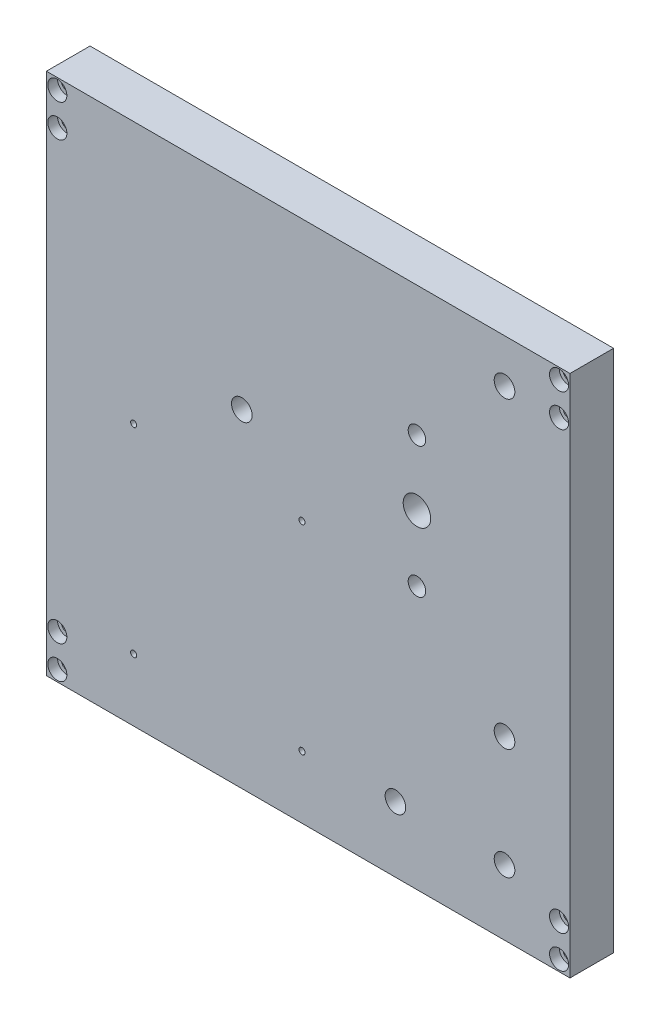
from build123d import *

# Parameters (mm, degrees)
SKETCH1_W                                      = 152.4
SKETCH1_H                                      = 152.4
BOSS_EXTRUDE1_DEPTH                            = 12.7
F_2_56_TAPPED_HOLE1_D                          = 1.778
CBORE_FOR_4_SOCKET_HEAD_CAP_SCREW1_D           = 3.2639
CBORE_FOR_4_SOCKET_HEAD_CAP_SCREW1_CBORE_D     = 5.55752
CBORE_FOR_4_SOCKET_HEAD_CAP_SCREW1_CBORE_DEPTH = 2.8448
F_6_0MM_DOWEL_HOLE1_D                          = 6
F_8_0MM_DOWEL_HOLE1_D                          = 8
F_1_4_20_TAPPED_HOLE1_D                        = 5.1054


with BuildPart() as part:
    # Sketch1 → Boss-Extrude1 (new body)
    with BuildSketch(Plane.XY):
        Rectangle(SKETCH1_W, SKETCH1_H)
    extrude(amount=BOSS_EXTRUDE1_DEPTH)

    # #2-56 Tapped Hole1 (through all)
    with Locations(Plane.XY.offset(12.7)):
        with Locations((-50.8, 0), (-50.8, -58), (-1.8, -58), (-1.8, 0)):
            Hole(F_2_56_TAPPED_HOLE1_D / 2)

    # CBORE for #4 Socket Head Cap Screw1 (through all)
    with Locations(Plane.XY.offset(12.7)):
        with Locations((-73.025, 63.5), (-73.025, 73.025), (73.025, 63.5), (73.025, 73.025), (73.025, -63.5), (73.025, -73.025), (-73.025, -63.5), (-73.025, -73.025)):
            CounterBoreHole(CBORE_FOR_4_SOCKET_HEAD_CAP_SCREW1_D / 2, CBORE_FOR_4_SOCKET_HEAD_CAP_SCREW1_CBORE_D / 2, CBORE_FOR_4_SOCKET_HEAD_CAP_SCREW1_CBORE_DEPTH)

    # Ø6.0mm Dowel Hole1 (through all)
    with Locations(Plane.XY.offset(12.7)):
        with Locations((57.15, 63.5), (57.15, -24.801), (-19.32090918, 19.3495), (57.15, -57.15), (25.4, -57.15)):
            Hole(F_6_0MM_DOWEL_HOLE1_D / 2)

    # Ø8.0mm Dowel Hole1 (through all)
    with Locations(Plane.XY.offset(12.7)):
        with Locations((31.65969694, 19.3495)):
            Hole(F_8_0MM_DOWEL_HOLE1_D / 2)

    # 1/4-20 Tapped Hole1 (through all)
    with Locations(Plane.XY.offset(12.7)):
        with Locations((31.65969694, 0.2995), (31.65969694, 38.3995)):
            Hole(F_1_4_20_TAPPED_HOLE1_D / 2)


solid = part.part
